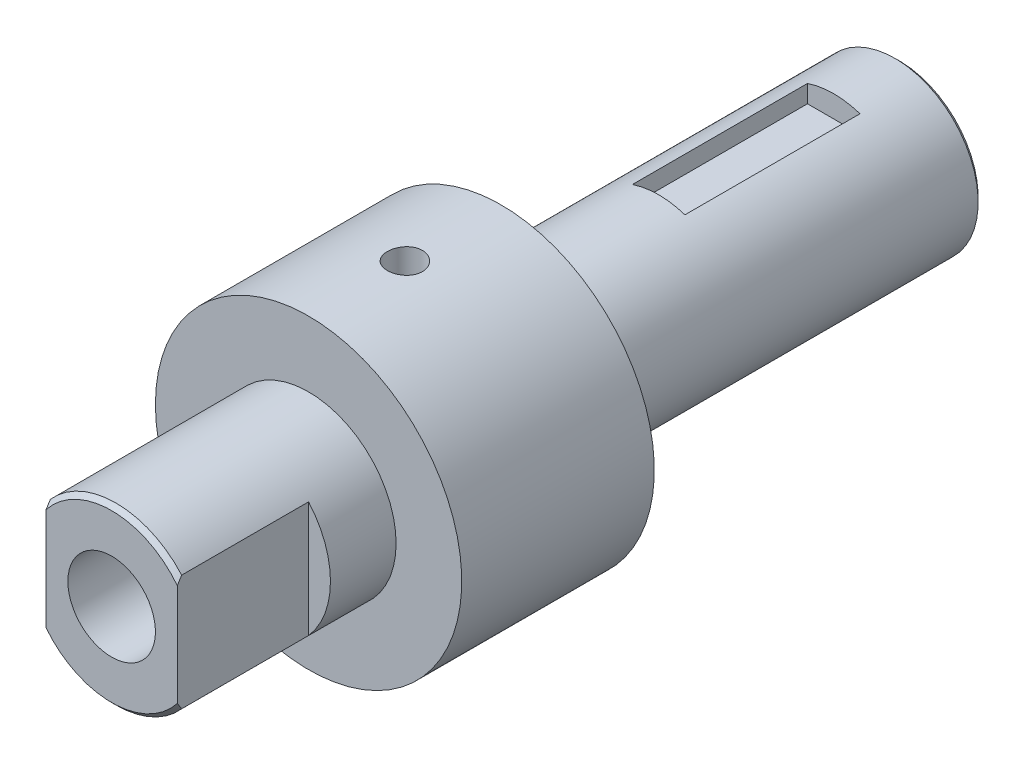
from build123d import *

# Parameters (mm, degrees)
SKETCH_1_R          = 20
EXTRUDE_1_DEPTH     = 45
SKETCH_3_R          = 35
EXTRUDE_2_DEPTH     = 44
SKETCH_4_R          = 19
EXTRUDE_3_DEPTH     = 91
SKETCH_5_R          = 4
CUT_EXTRUDE_1_DEPTH = 91
SKETCH_6_R          = 10
CUT_EXTRUDE_2_DEPTH = 180
CUT_EXTRUDE_3_DEPTH = 30
CHAMFER_1_SIZE      = 1
SKETCH_8_W          = 12
SKETCH_8_H          = 40
CUT_EXTRUDE_4_DEPTH = 5


with BuildPart() as part:
    # Эскиз1 → Бобышка-Вытянуть1 (new body)
    with BuildSketch(Plane.XY):
        Circle(SKETCH_1_R)
    extrude(amount=-EXTRUDE_1_DEPTH)

    # Эскиз3 → Бобышка-Вытянуть2 (add)
    with BuildSketch(Plane(origin=(0, 0, -45), x_dir=(-1, 0, 0), z_dir=(0, 0, -1))):
        Circle(SKETCH_3_R)
    extrude(amount=EXTRUDE_2_DEPTH)

    # Эскиз4 → Бобышка-Вытянуть3 (add)
    with BuildSketch(Plane(origin=(0, 0, -89), x_dir=(-1, 0, 0), z_dir=(0, 0, -1))):
        Circle(SKETCH_4_R)
    extrude(amount=EXTRUDE_3_DEPTH)

    # Эскиз5 → Вырез-Вытянуть1 (cut)
    with BuildSketch(Plane(origin=(0, 35, 0), x_dir=(1, 0, 0), z_dir=(0, 1, 0))):
        with Locations((0, 67)):
            Circle(SKETCH_5_R)
    extrude(amount=-CUT_EXTRUDE_1_DEPTH, mode=Mode.SUBTRACT)

    # Эскиз6 → Вырез-Вытянуть2 (cut)
    with BuildSketch(Plane(origin=(0, 0, -180), x_dir=(-1, 0, 0), z_dir=(0, 0, -1))):
        Circle(SKETCH_6_R)
    extrude(amount=-CUT_EXTRUDE_2_DEPTH, mode=Mode.SUBTRACT)

    # Эскиз7 → Вырез-Вытянуть3 (cut)
    with BuildSketch(Plane.XY):
        with BuildLine():
            Line((-15, 13.228756555), (-15, -13.228756555))
            ThreePointArc((-15, -13.228756555), (-20, 0), (-15, 13.228756555))
        make_face()
        with BuildLine():
            Line((15, 13.228756555), (15, -13.228756555))
            ThreePointArc((15, -13.228756555), (20, 0), (15, 13.228756555))
        make_face()
    extrude(amount=-CUT_EXTRUDE_3_DEPTH, mode=Mode.SUBTRACT)

    # Фаска1
    chamfer_1_edges = [part.edges().sort_by_distance(p)[0] for p in [
        (19, 0, -180),
        (0, 20, 0),
        (0, -20, 0),
    ]]
    chamfer(chamfer_1_edges, length=CHAMFER_1_SIZE)

    # Эскиз8 → Вырез-Вытянуть4 (cut)
    with BuildSketch(Plane(origin=(0, 19, 0), x_dir=(1, 0, 0), z_dir=(0, 1, 0))):
        with Locations((0, 145)):
            Rectangle(SKETCH_8_W, SKETCH_8_H)
    extrude(amount=-CUT_EXTRUDE_4_DEPTH, mode=Mode.SUBTRACT)


solid = part.part
